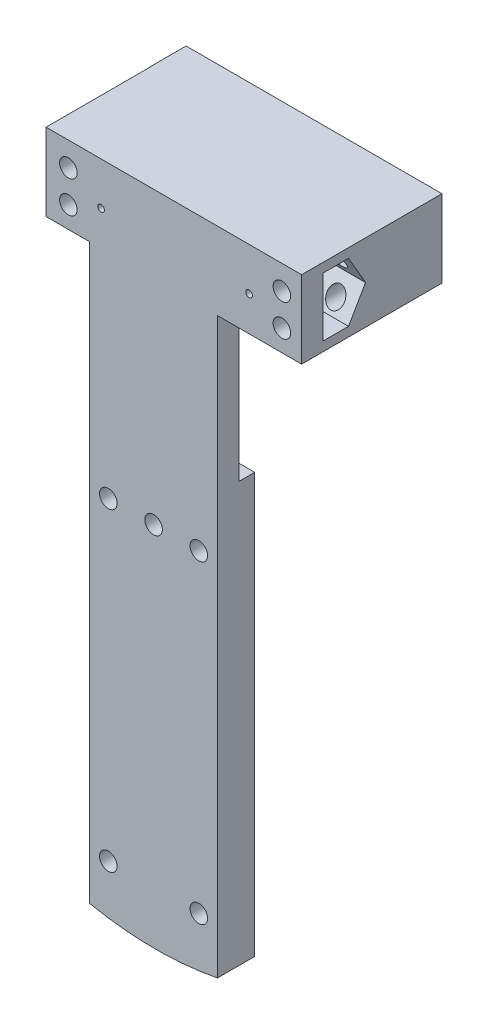
from build123d import *

# Parameters (mm, degrees)
BOSS_EXTRUDE1_DEPTH = 15.6
BOSS_EXTRUDE2_DEPTH = 6.75
BOSS_EXTRUDE3_DEPTH = 4
BOSS_EXTRUDE4_DEPTH = 3
SKETCH5_R           = 1.65
CUT_EXTRUDE1_DEPTH  = 8
SKETCH6_R           = 1.65
CUT_EXTRUDE2_DEPTH  = 27.35
CUT_EXTRUDE3_START  = -3
CUT_EXTRUDE3_DEPTH  = 2.6
CUT_EXTRUDE4_DEPTH  = 20
SKETCH9_W           = 15.8100889
SKETCH9_H           = 107.753083684
SKETCH9_W_2         = 8.2399111
SKETCH9_H_2         = 107.633309651
CUT_EXTRUDE5_DEPTH  = 10
SKETCH10_R          = 0.625
CUT_EXTRUDE6_DEPTH  = 30


with BuildPart() as part:
    # Sketch1 → Boss-Extrude1 (new body)
    with BuildSketch(Plane.XY):
        Polygon((-11.65, 6.6), (11.35, 6.6), (11.35, -6.2), (23.85, -6.2), (23.85, 8.35), (-24.15, 8.35), (-24.15, -6.2), (-11.65, -6.2), align=None)
    extrude(amount=-BOSS_EXTRUDE1_DEPTH)

    # Sketch2 → Boss-Extrude2 (add)
    with BuildSketch(Plane(origin=(0, 0, -15.6), x_dir=(-1, 0, 0), z_dir=(0, 0, -1))):
        Polygon((-16.2399111, -6.2), (-23.85, -6.2), (-23.85, 8.35), (24.2, 8.35), (24.2, -6.2), (16.0600889, -6.2), (16.0600889, 6.6), (-16.2399111, 6.6), align=None)
    extrude(amount=BOSS_EXTRUDE2_DEPTH)

    # Sketch3 → Boss-Extrude3 (add)
    with BuildSketch(Plane.XY):
        with BuildLine():
            Line((-24.15, 8.35), (23.85, 8.35))
            Line((23.85, 8.35), (23.85, 1.000334142))
            Line((23.85, 1.000334142), (23.85, -108.560334142))
            ThreePointArc((23.85, -108.560334142), (0.155860803, -114.961112509), (-24.15, -111.554159822))
            Line((-24.15, -111.554159822), (-24.15, 3.741161814))
            Line((-24.15, 3.741161814), (-24.15, 8.35))
        make_face()
    extrude(amount=BOSS_EXTRUDE3_DEPTH)

    # Sketch4 → Boss-Extrude4 (add)
    with BuildSketch(Plane(origin=(0, 0, 0), x_dir=(-1, 0, 0), z_dir=(0, 0, -1))):
        with BuildLine():
            ThreePointArc((10.093422233, -114.741481463), (13.037755905, -114.358456249), (15.9600889, -113.833309651))
            Line((15.9600889, -113.833309651), (15.9600889, -35.2))
            Line((15.9600889, -35.2), (10.093422233, -35.2))
            Line((10.093422233, -35.2), (10.093422233, -114.741481463))
        make_face()
        with BuildLine():
            ThreePointArc((1.026755567, -115.023412344), (3.960432973, -115.079264216), (6.893422233, -114.994667814))
            Line((6.893422233, -114.994667814), (6.893422233, -35.2))
            Line((6.893422233, -35.2), (1.026755567, -35.2))
            Line((1.026755567, -35.2), (1.026755567, -115.023412344))
        make_face()
        with BuildLine():
            ThreePointArc((-8.0399111, -113.953083684), (-5.116842896, -114.448405849), (-2.173244433, -114.801817592))
            Line((-2.173244433, -114.801817592), (-2.173244433, -35.2))
            Line((-2.173244433, -35.2), (-8.0399111, -35.2))
            Line((-8.0399111, -35.2), (-8.0399111, -113.953083684))
        make_face()
    extrude(amount=BOSS_EXTRUDE4_DEPTH)

    # Sketch5 → Cut-Extrude1 (cut, through all)
    with BuildSketch(Plane(origin=(0, 0, -3), x_dir=(-1, 0, 0), z_dir=(0, 0, -1))):
        with Locations((3.9600889, -46.2)):
            Circle(SKETCH5_R)
        with Locations((12.4600889, -46.2)):
            Circle(SKETCH5_R)
        with Locations((-4.5399111, -46.2)):
            Circle(SKETCH5_R)
        with Locations((12.4600889, -105.2)):
            Circle(SKETCH5_R)
        with Locations((-4.5399111, -105.2)):
            Circle(SKETCH5_R)
    extrude(amount=-CUT_EXTRUDE1_DEPTH, mode=Mode.SUBTRACT)

    # Sketch6 → Cut-Extrude2 (cut, through all)
    with BuildSketch(Plane(origin=(0, 0, -22.35), x_dir=(-1, 0, 0), z_dir=(0, 0, -1))):
        with Locations((-20.1399111, -2.18)):
            Circle(SKETCH6_R)
        with Locations((-20.1399111, 3.82)):
            Circle(SKETCH6_R)
        with Locations((19.9600889, -2.18)):
            Circle(SKETCH6_R)
        with Locations((19.9600889, 3.82)):
            Circle(SKETCH6_R)
    extrude(amount=-CUT_EXTRUDE2_DEPTH, mode=Mode.SUBTRACT)

    # Sketch7 → Cut-Extrude3 (cut)
    with BuildSketch(Plane(origin=(0, 0, -22.35), x_dir=(-1, 0, 0), z_dir=(0, 0, -1)).offset(CUT_EXTRUDE3_START)):
        Polygon((18.314640633, 0.67), (16.669192365, -2.18), (18.314640633, -5.03), (21.605537167, -5.03), (23.250985434, -2.18), (21.605537167, 0.67), align=None)
        Polygon((21.605537167, 6.67), (18.314640633, 6.67), (16.669192365, 3.82), (18.314640633, 0.97), (21.605537167, 0.97), (23.250985434, 3.82), align=None)
        Polygon((-21.785359367, 6.67), (-23.430807635, 3.82), (-21.785359367, 0.97), (-18.494462833, 0.97), (-16.849014566, 3.82), (-18.494462833, 6.67), align=None)
        Polygon((-21.785359367, 0.67), (-23.430807635, -2.18), (-21.785359367, -5.03), (-18.494462833, -5.03), (-16.849014566, -2.18), (-18.494462833, 0.67), align=None)
    extrude(amount=-CUT_EXTRUDE3_DEPTH, mode=Mode.SUBTRACT)

    # Sketch8 → Cut-Extrude4 (cut)
    with BuildSketch(Plane.ZY.offset(-11.35)):
        Polygon((0, 6.6), (-4.810139763, 6.6), (-8, 1.075), (-4.810139763, -4.45), (0, -4.45), align=None)
    extrude(amount=-CUT_EXTRUDE4_DEPTH, mode=Mode.SUBTRACT)

    # Sketch9 → Cut-Extrude5 (cut)
    with BuildSketch(Plane(origin=(0, 0, 0), x_dir=(-1, 0, 0), z_dir=(0, 0, -1))):
        with Locations((-15.94495555, -60.076541842)):
            Rectangle(SKETCH9_W, SKETCH9_H)
        with Locations((20.08004445, -60.016654826)):
            Rectangle(SKETCH9_W_2, SKETCH9_H_2)
    extrude(amount=-CUT_EXTRUDE5_DEPTH, mode=Mode.SUBTRACT)

    # Sketch10 → Cut-Extrude6 (cut)
    with BuildSketch(Plane(origin=(0, 0, -15.6), x_dir=(-1, 0, 0), z_dir=(0, 0, -1))):
        with Locations((13.8100889, 0.32)):
            Circle(SKETCH10_R)
        with Locations((-13.9899111, 0.32)):
            Circle(SKETCH10_R)
    extrude(amount=-CUT_EXTRUDE6_DEPTH, mode=Mode.SUBTRACT)


solid = part.part
